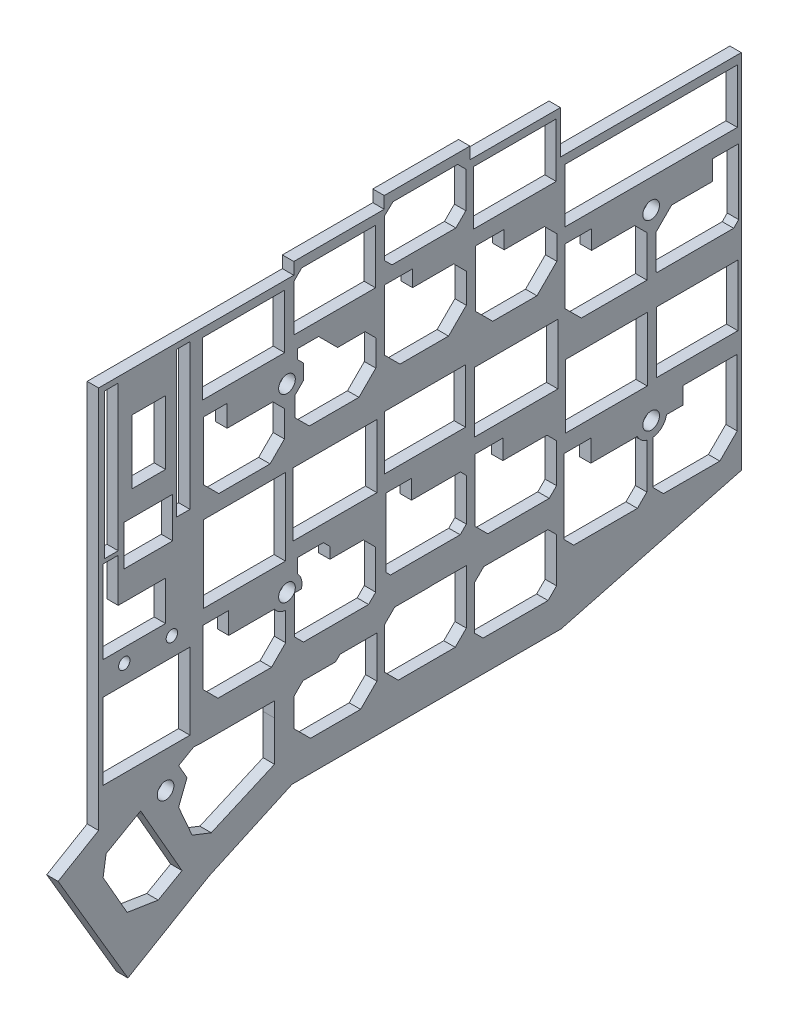
from build123d import *

# Parameters (mm, degrees)
SKETCH_1_R      = 1.75
SKETCH_1_R_2    = 1.195588846
SKETCH_1_W      = 17.169646596
SKETCH_1_H      = 13.401169178
SKETCH_1_W_2    = 17.141379501
SKETCH_1_H_2    = 12.863226362
SKETCH_1_W_3    = 17.538210896
SKETCH_1_H_3    = 12.684867068
SKETCH_1_W_4    = 17.040873724
SKETCH_1_H_4    = 11.374280562
SKETCH_1_W_5    = 17.162181977
SKETCH_1_H_5    = 16.140097757
SKETCH_1_W_6    = 17.67039471
SKETCH_1_H_6    = 13.319944222
SKETCH_1_W_7    = 17.245264615
SKETCH_1_W_8    = 17.388353154
SKETCH_1_W_9    = 2.808356134
SKETCH_1_H_7    = 30.502524416
SKETCH_1_W_10   = 7.052250026
SKETCH_1_H_8    = 13.431773701
SKETCH_1_W_11   = 2.889470686
SKETCH_1_W_12   = 10.272810968
SKETCH_1_H_9    = 8.480842068
SKETCH_1_W_13   = 18.277633843
SKETCH_1_H_10   = 16.036952758
EXTRUDE_1_DEPTH = 2.4


with BuildPart() as part:
    # Эскиз1 → Бобышка-Вытянуть1 (new body)
    with BuildSketch(Plane(origin=(0, 0, 0), x_dir=(0, 0, -1), z_dir=(1, 0, 0))):
        Polygon((0, 0), (0, -80.5), (-8.5, -85.5), (6.153232532, -110.410495305), (23.153232532, -100.410495305), (40.653232532, -92.410495305), (97.153232532, -92.410495305), (135, -82.5), (135, -6.5), (97, -6.5), (97, 2.5), (78, 2.5), (78, 5), (60, 5), (60, 2.5), (41, 2.5), (41, 0), align=None)
        with Locations((39.57, -56.958)):
            Circle(SKETCH_1_R, mode=Mode.SUBTRACT)
        with Locations((116.07, -63.958)):
            Circle(SKETCH_1_R, mode=Mode.SUBTRACT)
        with Locations((116.07, -25.658)):
            Circle(SKETCH_1_R, mode=Mode.SUBTRACT)
        with Locations((39.57, -19.048)):
            Circle(SKETCH_1_R, mode=Mode.SUBTRACT)
        with Locations((15.389685628, -52.783446411)):
            Circle(SKETCH_1_R_2, mode=Mode.SUBTRACT)
        with Locations((5.398365175, -52.807577232)):
            Circle(SKETCH_1_R_2, mode=Mode.SUBTRACT)
        with Locations((14.07, -80.258)):
            Circle(SKETCH_1_R, mode=Mode.SUBTRACT)
        with BuildLine():
            Line((41.175087183, -59.666861797), (41.175087183, -57.87116164))
            Line((41.175087183, -57.87116164), (42.583365713, -57.87116164))
            ThreePointArc((42.583365713, -57.87116164), (42.615493451, -56.158495943), (41.746265162, -54.682454561))
            Line((41.746265162, -54.682454561), (41.746265162, -51.743354631))
            Line((41.746265162, -51.743354631), (47.211554008, -51.743354631))
            Line((47.211554008, -51.743354631), (48.587777015, -53.119577638))
            Line((48.587777015, -53.119577638), (48.587777015, -55.470651177))
            Line((48.587777015, -55.470651177), (55.621107258, -55.470651177))
            Line((55.621107258, -55.470651177), (58.206672814, -58.056216733))
            Line((58.206672814, -58.056216733), (58.206672814, -66.253784685))
            Line((58.206672814, -66.253784685), (56.714186027, -67.746271472))
            Line((56.714186027, -67.746271472), (43.030078783, -67.746271472))
            Line((43.030078783, -67.746271472), (41.175087183, -65.891279871))
            Line((41.175087183, -65.891279871), (41.175087183, -59.666861797))
        make_face(mode=Mode.SUBTRACT)
        with Locations((106.659542531, -50.567497973)):
            Rectangle(SKETCH_1_W, SKETCH_1_H, mode=Mode.SUBTRACT)
        with Locations((125.71049499, -50.298526565)):
            Rectangle(SKETCH_1_W_2, SKETCH_1_H_2, mode=Mode.SUBTRACT)
        with Locations((87.712627862, -42.078999024)):
            Rectangle(SKETCH_1_W_3, SKETCH_1_H_3, mode=Mode.SUBTRACT)
        with Locations((68.554819797, -40.000500332)):
            Rectangle(SKETCH_1_W_4, SKETCH_1_H_4, mode=Mode.SUBTRACT)
        with Locations((30.669266832, -43.056032785)):
            Rectangle(SKETCH_1_W_5, SKETCH_1_H_5, mode=Mode.SUBTRACT)
        with Locations((49.623645929, -41.619044946)):
            Rectangle(SKETCH_1_W_6, SKETCH_1_H_6, mode=Mode.SUBTRACT)
        with Locations((30.462379832, -7.439291973)):
            Rectangle(SKETCH_1_W_7, SKETCH_1_H_4, mode=Mode.SUBTRACT)
        Polygon((114.42486942, -8.317278152), (97.934490117, -8.317278152), (97.934490117, -19.691558714), (115.181874592, -19.691558714), (134.172131343, -19.691558714), (134.172131343, -8.317278152), align=None, mode=Mode.SUBTRACT)
        Polygon((75.423069219, 2.949575951), (61.840237519, 2.949575951), (60.057474173, 1.281506465), (60.057474173, -6.859054191), (61.623124593, -8.424704611), (75.047835645, -8.424704611), (77.140090472, -6.332449784), (77.140090472, 1.232554698), align=None, mode=Mode.SUBTRACT)
        Polygon((58.174266715, 0.501219129), (42.657683811, 0.501219129), (41.013785657, -1.142679026), (41.013785657, -10.873061434), (58.174266715, -10.873061434), align=None, mode=Mode.SUBTRACT)
        with Locations((87.430115145, -4.807350473)):
            Rectangle(SKETCH_1_W_8, SKETCH_1_H_4, mode=Mode.SUBTRACT)
        Polygon((134.445467428, -22.788358717), (134.445467428, -36.60294116), (133.397262053, -37.651146535), (117.319474065, -37.651146535), (117.033113418, -37.364785888), (117.033113418, -30.253110389), (120.371379108, -26.914844699), (128.909808884, -26.914844699), (128.909808884, -22.788358717), align=None, mode=Mode.SUBTRACT)
        with Locations((17.791376654, -16.428884309)):
            Rectangle(SKETCH_1_W_9, SKETCH_1_H_7, mode=Mode.SUBTRACT)
        with Locations((10.543874987, -15.140591462)):
            Rectangle(SKETCH_1_W_10, SKETCH_1_H_8, mode=Mode.SUBTRACT)
        with Locations((2.678265443, -16.428884309)):
            Rectangle(SKETCH_1_W_11, SKETCH_1_H_7, mode=Mode.SUBTRACT)
        with Locations((10.434782025, -31.359442405)):
            Rectangle(SKETCH_1_W_12, SKETCH_1_H_9, mode=Mode.SUBTRACT)
        Polygon((4.123000786, -32.492542395), (0.917920878, -32.492542395), (0.917920878, -49.892211687), (14.07, -49.892211687), (14.07, -41.621729525), (4.123000786, -41.621729525), align=None, mode=Mode.SUBTRACT)
        Polygon((97.934490117, -22.788358717), (97.934490117, -34.525264826), (101.390322304, -37.981097014), (115.181874592, -37.981097014), (115.181874592, -29.340982715), (112.606155597, -26.765263721), (103.539061517, -26.765263721), (103.539061517, -22.788358717), align=None, mode=Mode.SUBTRACT)
        Polygon((79.180110888, -13.746261571), (79.180110888, -25.658), (82.792774606, -29.270663718), (92.078948152, -29.270663718), (96.254633409, -25.09497846), (96.254633409, -20.076315537), (93.652633012, -17.47431514), (85.190904072, -17.47431514), (85.190904072, -13.746261571), align=None, mode=Mode.SUBTRACT)
        Polygon((60.057474173, -11.543336439), (60.057474173, -24.064869078), (63.312586644, -27.319981549), (73.506972129, -27.319981549), (77.243421659, -23.583532019), (77.243421659, -17.384016554), (74.598321167, -14.738916063), (65.950874847, -14.738916063), (65.950874847, -11.296606732), (60.057474173, -11.296606732), align=None, mode=Mode.SUBTRACT)
        Polygon((41.203889279, -21.990928419), (41.203889279, -25.99732341), (44.255261796, -29.048695926), (54.679222497, -29.048695926), (58.221966789, -25.505951635), (58.221966789, -19.991138911), (55.979025188, -17.74819731), (50.206805869, -17.74819731), (46.20487013, -13.746261571), (41.746265162, -13.746261571), (41.746265162, -15.693731888), (43.001832487, -16.949299213), (43.001832487, -20.192985211), align=None, mode=Mode.SUBTRACT)
        Polygon((22.088175844, -16.292883302), (22.088175844, -28.227019207), (22.088175844, -28.678389313), (25.24269809, -31.832911558), (36.016307307, -31.832911558), (39.040036719, -28.809182147), (39.040036719, -23.270549167), (36.608400243, -20.838912691), (27.002113107, -20.838912691), (27.002113107, -16.292883302), align=None, mode=Mode.SUBTRACT)
        with BuildLine():
            Line((134.142942163, -60.937616343), (134.142942163, -74.900317023))
            Line((134.142942163, -74.900317023), (130.49124589, -78.552013295))
            Line((130.49124589, -78.552013295), (118.652571938, -78.552013295))
            Line((118.652571938, -78.552013295), (116.436686674, -76.336128032))
            Line((116.436686674, -76.336128032), (116.436686674, -67.195762578))
            ThreePointArc((116.436686674, -67.195762578), (118.309987593, -66.324436396), (119.282770405, -64.501757256))
            Line((119.282770405, -64.501757256), (122.704601682, -64.501757256))
            Line((122.704601682, -64.501757256), (122.704601682, -60.937616343))
            Line((122.704601682, -60.937616343), (134.142942163, -60.937616343))
        make_face(mode=Mode.SUBTRACT)
        with BuildLine():
            Line((115.151593008, -67.084354783), (115.151593008, -76.516497938))
            Line((115.151593008, -76.516497938), (113.174976526, -78.49311442))
            Line((113.174976526, -78.49311442), (99.804931814, -78.49311442))
            Line((99.804931814, -78.49311442), (97.748457307, -76.436639913))
            Line((97.748457307, -76.436639913), (97.748457307, -60.819286297))
            Line((97.748457307, -60.819286297), (103.395763064, -60.819286297))
            Line((103.395763064, -60.819286297), (103.395763064, -65.390586437))
            Line((103.395763064, -65.390586437), (113.143353159, -65.390586437))
            ThreePointArc((113.143353159, -65.390586437), (113.969209066, -66.448831805), (115.151593008, -67.084354783))
        make_face(mode=Mode.SUBTRACT)
        Polygon((94.390100577, -72.96326942), (96.191542527, -74.764711371), (96.191542527, -84.098410017), (94.409265216, -85.880687328), (80.761379121, -85.880687328), (78.943522414, -84.062830621), (78.943522414, -74.907188822), (80.902842654, -72.947868581), (89.328661956, -72.947868581), (89.307183628, -72.96326942), (92.078948152, -72.96326942), align=None, mode=Mode.SUBTRACT)
        Polygon((96.191542527, -57.695364402), (96.191542527, -63.958), (96.191542527, -65.877985117), (94.654300063, -67.415227581), (81.768198723, -67.415227581), (79.038387089, -64.685415947), (79.038387089, -51.579195053), (84.910996524, -51.579195053), (84.910996524, -55.683854121), (94.180032246, -55.683854121), align=None, mode=Mode.SUBTRACT)
        Polygon((60.333227523, -49.292492296), (60.333227523, -63.708322413), (61.310321057, -64.685415947), (75.950178754, -64.685415947), (77.239669067, -63.395925635), (77.239669067, -54.523457735), (76.005985051, -53.289773719), (65.729673934, -53.289773719), (65.729673934, -49.292492296), align=None, mode=Mode.SUBTRACT)
        Polygon((77.239669067, -70.920039632), (77.239669067, -82.307915823), (74.911725785, -84.635859105), (62.948944728, -84.635859105), (60.034382935, -81.721297313), (60.034382935, -73.122841402), (62.191251201, -70.965973136), (69.670831392, -70.965973136), (69.670831392, -70.920039632), align=None, mode=Mode.SUBTRACT)
        Polygon((58.458843284, -74.190353498), (58.458843284, -82.561368263), (55.03350633, -85.986705217), (44.516479669, -85.986705217), (41.013785657, -82.484011204), (41.013785657, -76.628274478), (42.928991381, -74.713068753), (49.791296083, -74.713068753), (50.704878121, -73.799486715), (58.458843284, -73.799486715), align=None, mode=Mode.SUBTRACT)
        with BuildLine():
            Line((27.335015543, -54.140569928), (27.335015543, -58.693181301))
            Line((27.335015543, -58.693181301), (36.942571038, -58.693181301))
            ThreePointArc((36.942571038, -58.693181301), (37.959536913, -59.663669186), (39.297493889, -60.094873845))
            Line((39.297493889, -60.094873845), (39.297493889, -65.998669584))
            Line((39.297493889, -65.998669584), (36.313242652, -68.982920822))
            Line((36.313242652, -68.982920822), (25.082869742, -68.982920822))
            Line((25.082869742, -68.982920822), (21.913238984, -65.813290064))
            Line((21.913238984, -65.813290064), (21.913238984, -54.140569928))
            Line((21.913238984, -54.140569928), (27.335015543, -54.140569928))
        make_face(mode=Mode.SUBTRACT)
        with Locations((10.0567378, -64.748616125)):
            Rectangle(SKETCH_1_W_13, SKETCH_1_H_10, mode=Mode.SUBTRACT)
        Polygon((36.942571038, -75.377878816), (36.942571038, -78.507187925), (36.949231493, -78.500527469), (36.949231493, -86.932648509), (23.668701025, -92.748939226), (19.64926188, -91.177889407), (16.806158528, -84.686136755), (18.571471544, -80.169686573), (16.817955068, -77.103695427), (19.987700978, -75.290839024), (21.344934578, -75.377878816), align=None, mode=Mode.SUBTRACT)
        Polygon((9.476173509, -82.484588759), (17.527952186, -96.562974941), (12.527568373, -99.422818622), (6, -98.396281323), (0.948426962, -89.563699243), (1.587491711, -85.5), (8.832330014, -81.356497059), align=None, mode=Mode.SUBTRACT)
    extrude(amount=EXTRUDE_1_DEPTH)


solid = part.part
